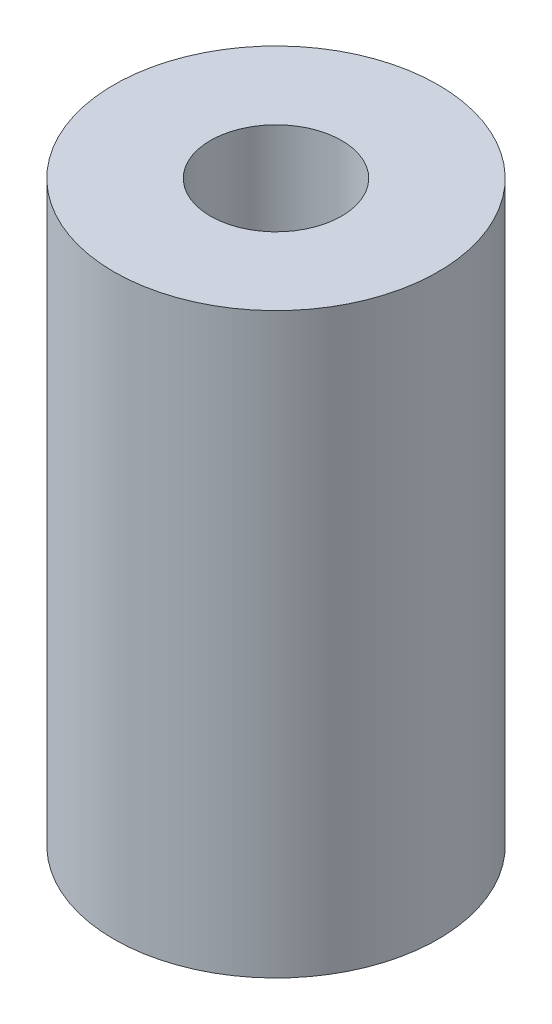
from build123d import *

# Parameters (mm, degrees)
SKETCH2_R      = 42.7355
SKETCH2_R_2    = 17.2974
EXTRUDE1_DEPTH = 152.4


with BuildPart() as part:
    # Sketch2 → Extrude1 (new body)
    with BuildSketch(Plane(origin=(0, 0, 0), x_dir=(1, 0, 0), z_dir=(0, 1, 0))):
        Circle(SKETCH2_R)
        Circle(SKETCH2_R_2, mode=Mode.SUBTRACT)
    extrude(amount=EXTRUDE1_DEPTH)


solid = part.part
